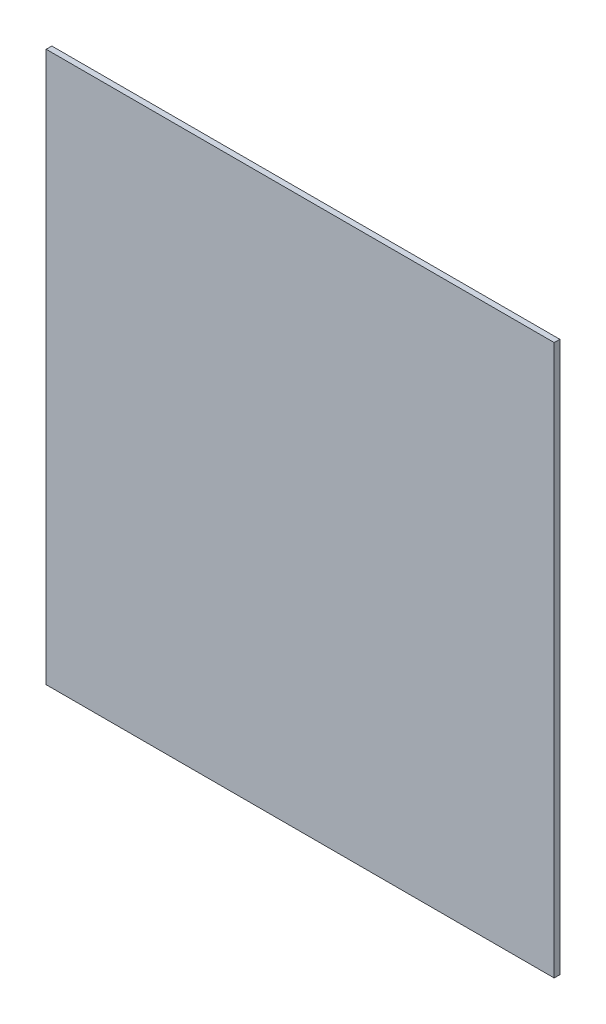
from build123d import *

# Parameters (mm, degrees)
SKETCH1_W           = 180
SKETCH1_H           = 195
BOSS_EXTRUDE1_DEPTH = 2


with BuildPart() as part:
    # Sketch1 → Boss-Extrude1 (new body)
    with BuildSketch(Plane.XY):
        with Locations((90, -97.5)):
            Rectangle(SKETCH1_W, SKETCH1_H)
    extrude(amount=BOSS_EXTRUDE1_DEPTH)


solid = part.part
